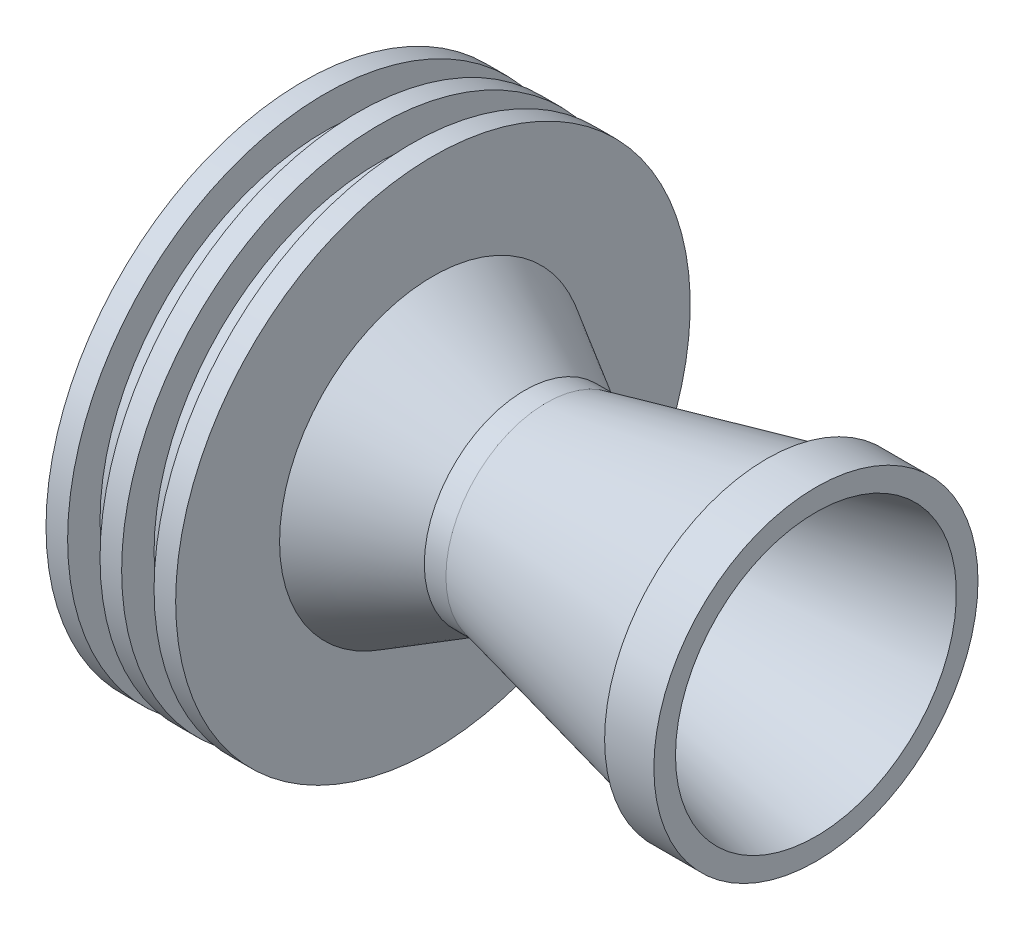
from build123d import *


with BuildPart() as part:
    # Esboço2 → Revolução1 (revolve)
    with BuildSketch(Plane.XY):
        Polygon((0, 23.8125), (2, 23.8125), (2, 20.8125), (5, 20.8125), (5, 23.8125), (7, 23.8125), (7, 20.8125), (10, 20.8125), (10, 23.8125), (12, 23.8125), (12, 20.8125), (12, 14.193697846), (20.49192648, 9.290881808), (22.49192648, 9.290881808), (42.889358319, 14), (42.889358319, 15), (47.44870541, 15), (47.44870541, 13), (21.459850164, 7), (20.459850164, 7), (0, 18.8125), (0, 20.8125), align=None)
    revolve(axis=Axis((-1000, 0, 0), (1, 0, 0)))


solid = part.part
